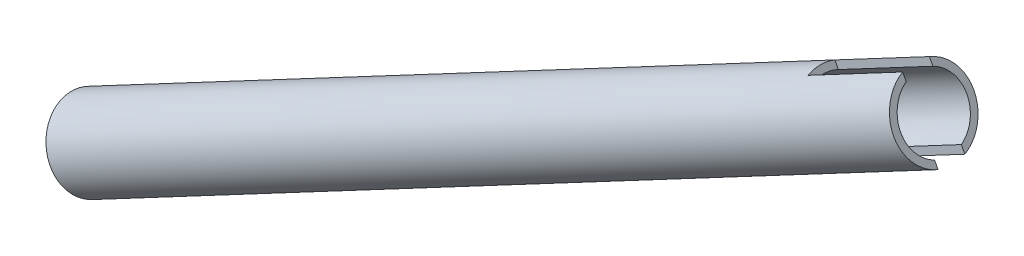
from build123d import *

# Parameters (mm, degrees)
CUT_EXTRUDE1_START = -3.175
CUT_EXTRUDE1_DEPTH = 6.35


with BuildPart() as part:
    # Sketch1 → Revolve1 (revolve)
    with BuildSketch(Plane.XY):
        Polygon((375.787435481, -136.289767997), (576.014178169, -30.052199471), (576.787998451, -31.510624365), (376.561255763, -137.74819289), align=None)
    revolve(axis=Axis((553.143743583, -33.273230716, 0), (0.883358506, 0.46869793, 0)))

    # Sketch2 → Cut-Extrude1 (cut)
    with BuildSketch(Plane.XY.offset(CUT_EXTRUDE1_START)):
        Polygon((545.421996828, -26.587572245), (554.350692395, -43.415551787), (576.787998451, -31.510624365), (567.859302885, -14.682644822), align=None)
    extrude(amount=CUT_EXTRUDE1_DEPTH, mode=Mode.SUBTRACT)


solid = part.part
